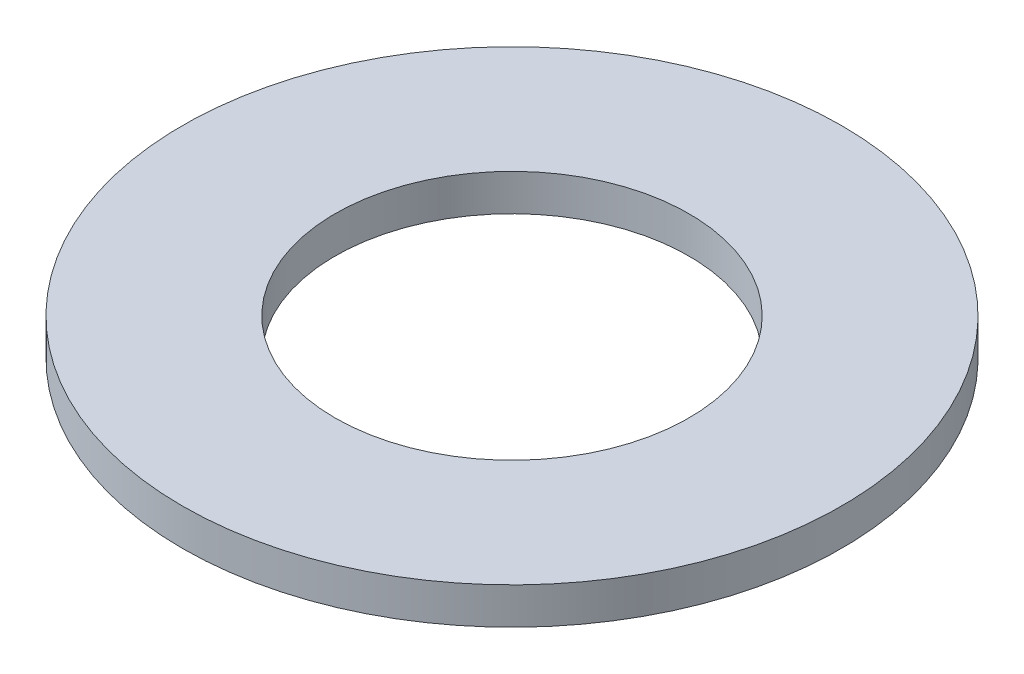
from build123d import *

# Parameters (mm, degrees)
SKETCH1_R           = 9.4615
SKETCH1_R_2         = 5.08
BOSS_EXTRUDE1_DEPTH = 1.0541


with BuildPart() as part:
    # Sketch1 → Boss-Extrude1 (new body)
    with BuildSketch(Plane(origin=(0, 0, 0), x_dir=(1, 0, 0), z_dir=(0, 1, 0))):
        Circle(SKETCH1_R)
        Circle(SKETCH1_R_2, mode=Mode.SUBTRACT)
    extrude(amount=BOSS_EXTRUDE1_DEPTH)


solid = part.part
